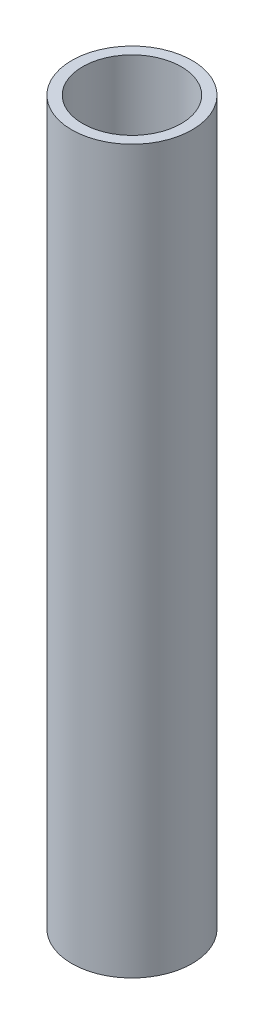
from build123d import *

# Parameters (mm, degrees)
SKETCH1_R           = 12.7
SKETCH1_R_2         = 10.414
BOSS_EXTRUDE1_DEPTH = 152.4


with BuildPart() as part:
    # Sketch1 → Boss-Extrude1 (new body)
    with BuildSketch(Plane(origin=(0, 0, 0), x_dir=(1, 0, 0), z_dir=(0, 1, 0))):
        Circle(SKETCH1_R)
        Circle(SKETCH1_R_2, mode=Mode.SUBTRACT)
    extrude(amount=BOSS_EXTRUDE1_DEPTH)


solid = part.part
